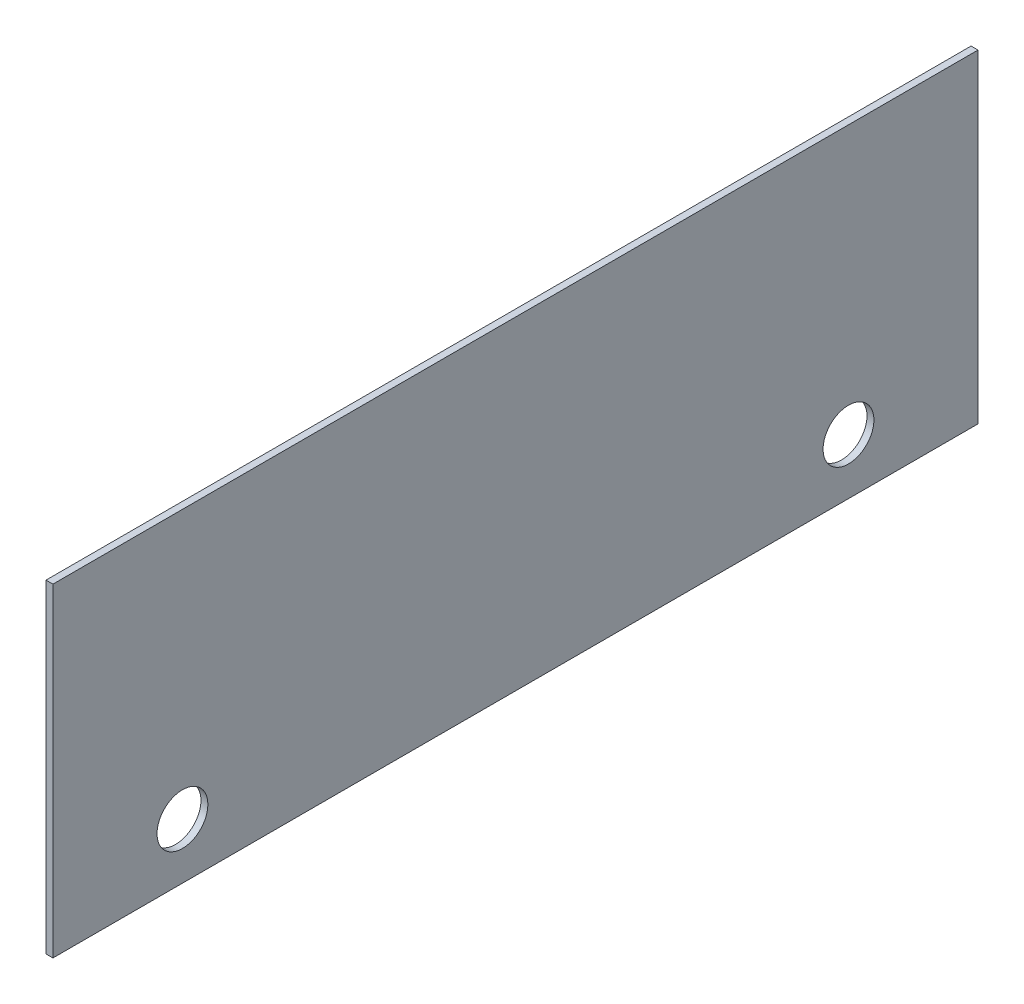
from build123d import *

# Parameters (mm, degrees)
SKETCH1_W           = 4.7625
SKETCH1_H           = 222.25
BOSS_EXTRUDE1_DEPTH = 635
SKETCH2_R           = 17.45
CUT_EXTRUDE1_DEPTH  = 5.7625


with BuildPart() as part:
    # Sketch1 → Boss-Extrude1 (new body)
    with BuildSketch(Plane.XY):
        with Locations((2.38125, 111.125)):
            Rectangle(SKETCH1_W, SKETCH1_H)
    extrude(amount=BOSS_EXTRUDE1_DEPTH)

    # Sketch2 → Cut-Extrude1 (cut, through all)
    with BuildSketch(Plane(origin=(4.7625, 0, 0), x_dir=(0, 0, -1), z_dir=(1, 0, 0))):
        with Locations((-546.1, 38.1)):
            Circle(SKETCH2_R)
        with Locations((-88.9, 38.1)):
            Circle(SKETCH2_R)
    extrude(amount=-CUT_EXTRUDE1_DEPTH, mode=Mode.SUBTRACT)


solid = part.part
